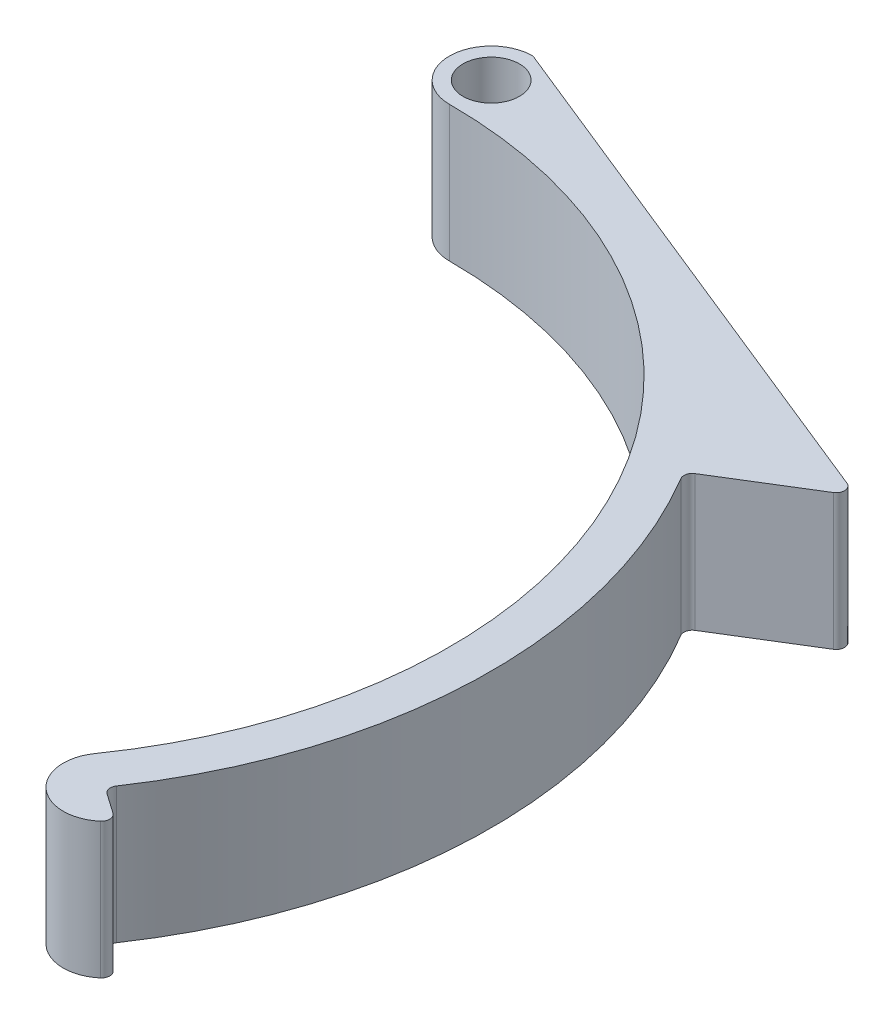
from build123d import *

# Parameters (mm, degrees)
SKETCH1_R           = 2.7
BOSS_EXTRUDE1_DEPTH = 13
FILLET1_R           = 0.8


with BuildPart() as part:
    # Sketch1 → Boss-Extrude1 (new body)
    with BuildSketch(Plane(origin=(0, 0, 0), x_dir=(1, 0, 0), z_dir=(0, 1, 0))):
        with BuildLine():
            Line((51.921017872, 32.018867925), (0, 53))
            ThreePointArc((0, 53), (-4, 49), (0, 45))
            ThreePointArc((0, 45), (39.915487493, 20.778687596), (36.861841993, -25.810939636))
            ThreePointArc((36.861841993, -25.810939636), (37.844144425, -31.381853558), (43.415058347, -30.399551127))
            Line((43.415058347, -30.399551127), (40.13845017, -28.105245381))
            ThreePointArc((40.13845017, -28.105245381), (48.97920595, -1.427369772), (41.707047143, 25.720074234))
            Line((41.707047143, 25.720074234), (51.921017872, 32.018867925))
        make_face()
        with Locations((0, 49)):
            Circle(SKETCH1_R, mode=Mode.SUBTRACT)
    extrude(amount=BOSS_EXTRUDE1_DEPTH)

    # Fillet1
    fillet1_edges = [part.edges().sort_by_distance(p)[0] for p in [
        (51.921017872, 6.5, -32.018867925),
        (41.707047143, 6.5, -25.720074234),
        (40.13845017, 6.5, 28.105245381),
        (43.415058347, 6.5, 30.399551127),
        (0, 6.5, -53),
    ]]
    fillet(fillet1_edges, radius=FILLET1_R)


solid = part.part
